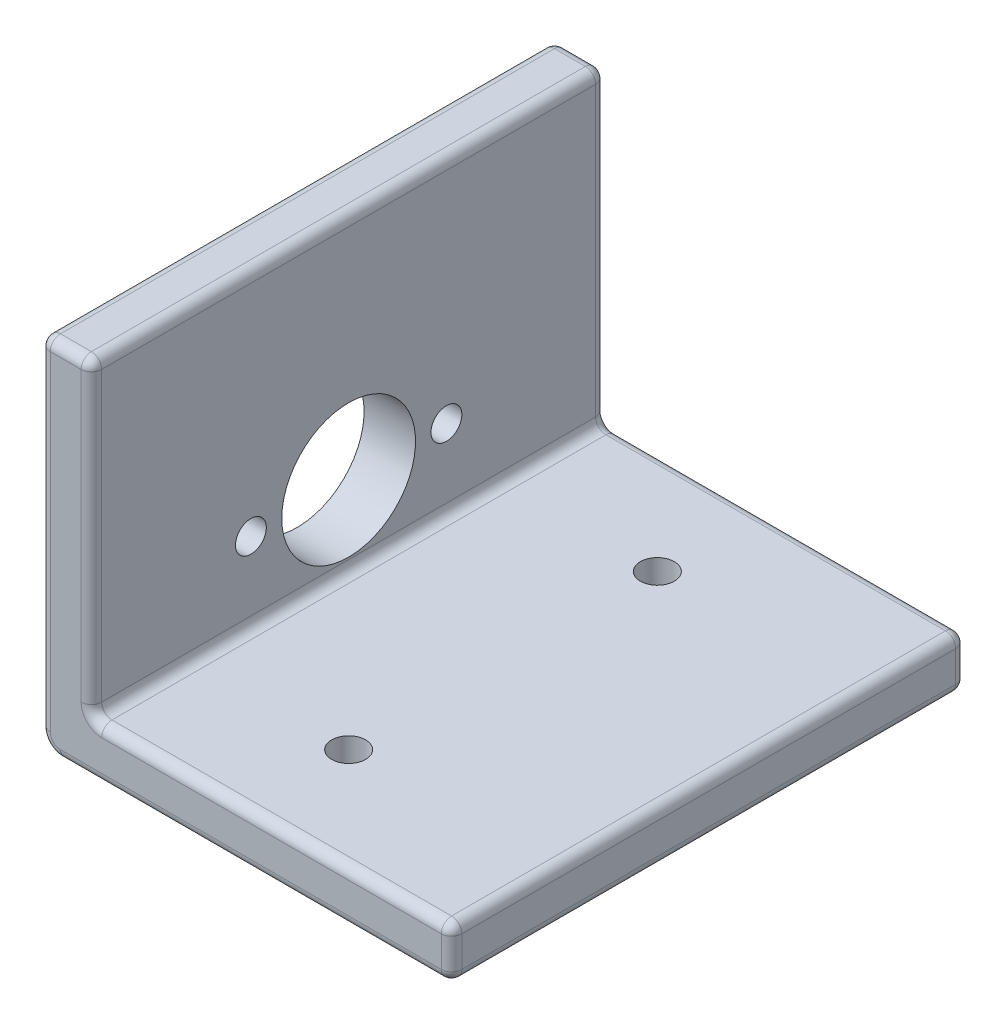
from build123d import *

# Parameters (mm, degrees)
BOSS_EXTRUDE1_DEPTH = 50
FILLET1_R           = 2
SKETCH2_R           = 6.5
SKETCH2_R_2         = 1.5
CUT_EXTRUDE1_DEPTH  = 20
SKETCH3_R           = 1.65
CUT_EXTRUDE2_DEPTH  = 20
FILLET2_R           = 1
FILLET3_R           = 1


with BuildPart() as part:
    # Sketch1 → Boss-Extrude1 (new body)
    with BuildSketch(Plane.XY):
        Polygon((0, 0), (0, 35), (5, 35), (5, 5), (40, 5), (40, 0), align=None)
    extrude(amount=BOSS_EXTRUDE1_DEPTH)

    # Fillet1
    fillet1_edges = [part.edges().sort_by_distance(p)[0] for p in [
        (0, 0, 25),
    ]]
    fillet(fillet1_edges, radius=FILLET1_R)

    # Sketch2 → Cut-Extrude1 (cut)
    with BuildSketch(Plane.ZY):
        with Locations((25, 12.7)):
            Circle(SKETCH2_R)
        with Locations((15.5, 12.7)):
            Circle(SKETCH2_R_2)
        with Locations((34.5, 12.7)):
            Circle(SKETCH2_R_2)
    extrude(amount=-CUT_EXTRUDE1_DEPTH, mode=Mode.SUBTRACT)

    # Sketch3 → Cut-Extrude2 (cut)
    with BuildSketch(Plane(origin=(0, 5, 0), x_dir=(1, 0, 0), z_dir=(0, 1, 0))):
        with Locations((20, -10)):
            Circle(SKETCH3_R)
        with Locations((20, -40)):
            Circle(SKETCH3_R)
    extrude(amount=-CUT_EXTRUDE2_DEPTH, mode=Mode.SUBTRACT)

    # Fillet2
    fillet2_edges = [part.edges().sort_by_distance(p)[0] for p in [
        (5, 5, 25),
    ]]
    fillet(fillet2_edges, radius=FILLET2_R)

    # Fillet3
    fillet3_edges = [part.edges().sort_by_distance(p)[0] for p in [
        (21, 0, 0),
        (0.585786438, 0.585786438, 0),
        (23, 5, 0),
        (5.292893219, 5.292893219, 0),
        (21, 0, 50),
        (0.585786438, 0.585786438, 50),
        (23, 5, 50),
        (5.292893219, 5.292893219, 50),
        (0, 18.5, 0),
        (5, 20.5, 0),
        (0, 18.5, 50),
        (5, 20.5, 50),
        (5, 35, 25),
        (0, 35, 25),
        (40, 0, 25),
        (40, 5, 25),
        (40, 2.5, 0),
        (40, 2.5, 50),
        (2.5, 35, 50),
        (2.5, 35, 0),
    ]]
    fillet(fillet3_edges, radius=FILLET3_R)


solid = part.part
